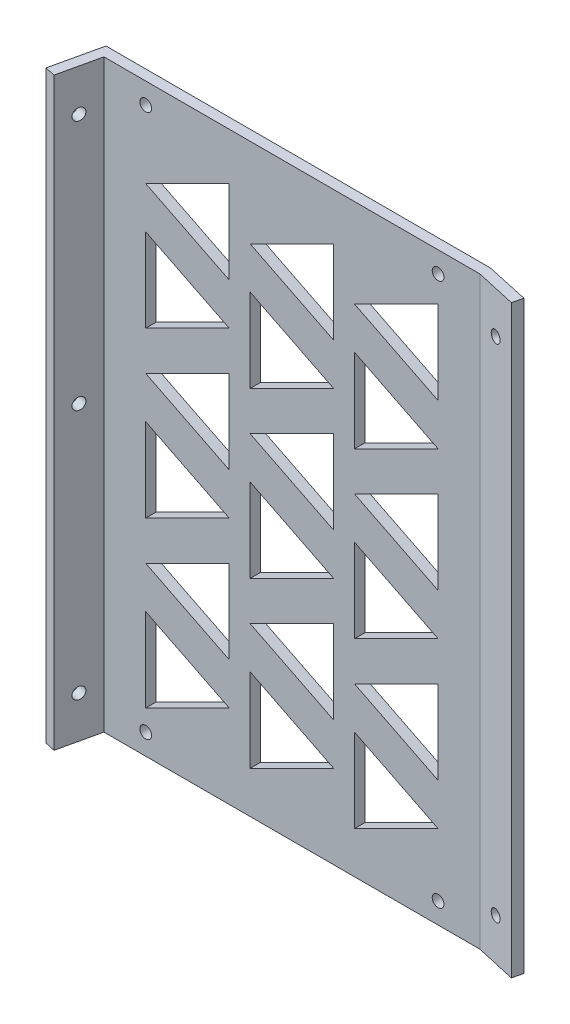
from build123d import *

# Parameters (mm, degrees)
SKETCH1_W              = 114.3
SKETCH1_H              = 177.8
BOSS_EXTRUDE1_DEPTH    = 3.175
BOSS_EXTRUDE2_DEPTH    = 177.8
SKETCH3_R              = 1.778
CUT_EXTRUDE1_DEPTH     = 203.2
CUT_EXTRUDE2_DEPTH     = 3.175
LPATTERN2_COUNT        = 3
LPATTERN2_PITCH        = 50
LPATTERN3_COUNT        = 3
LPATTERN3_PITCH        = 31.75
LPATTERN3_COPY_1_DEPTH = 3.175
LPATTERN3_COPY_2_DEPTH = 3.175
LPATTERN3_COPY_3_DEPTH = 3.175
LPATTERN3_COPY_4_DEPTH = 3.175
SKETCH5_R              = 1.778
CUT_EXTRUDE3_DEPTH     = 3.175
SKETCH6_R              = 1.778
CUT_EXTRUDE4_DEPTH     = 3.175


with BuildPart() as part:
    # Sketch1 → Boss-Extrude1 (new body)
    with BuildSketch(Plane.XY):
        with Locations((-57.15, -88.9)):
            Rectangle(SKETCH1_W, SKETCH1_H)
    extrude(amount=BOSS_EXTRUDE1_DEPTH)

    # Sketch2 → Boss-Extrude2 (add)
    with BuildSketch(Plane.XZ.offset(177.8)):
        Polygon((-114.3, 3.175), (-117.087804878, 15.565243902), (-120.185365854, 14.868292683), (-116.84, 0), (-114.3, 0), align=None)
        Polygon((0, 3.175), (0, 0), (13.087195122, 2.865243902), (12.390243902, 5.962804878), align=None)
    extrude(amount=-BOSS_EXTRUDE2_DEPTH)

    # Sketch3 → Cut-Extrude1 (cut)
    with BuildSketch(Plane(origin=(-108.112433076, 0, -24.325297442), x_dir=(0.219512195, 0, -0.975609756), z_dir=(0.975609756, 0, 0.219512195))):
        with Locations((-34.537804878, -165.1)):
            Circle(SKETCH3_R)
        with Locations((-34.537804878, -88.9)):
            Circle(SKETCH3_R)
        with Locations((-34.537804878, -12.7)):
            Circle(SKETCH3_R)
    extrude(amount=-CUT_EXTRUDE1_DEPTH, mode=Mode.SUBTRACT)

    # Sketch4 → Cut-Extrude2 (cut)
    with BuildSketch(Plane.XY.offset(3.175)):
        Polygon((-101.6, -165.1), (-101.6, -139.7), (-76.2, -152.4), align=None)
        Polygon((-101.6, -127), (-76.2, -139.7), (-76.2, -114.3), align=None)
    cut_extrude2 = extrude(amount=-CUT_EXTRUDE2_DEPTH, mode=Mode.SUBTRACT)

    # LPattern2: Cut-Extrude2 ×3
    with Locations(*[(0, i * LPATTERN2_PITCH, 0) for i in range(1, LPATTERN2_COUNT)]):
        add(cut_extrude2, mode=Mode.SUBTRACT)

    # LPattern3: Cut-Extrude2 ×3
    with Locations(*[(i * LPATTERN3_PITCH, 0, 0) for i in range(1, LPATTERN3_COUNT)]):
        add(cut_extrude2, mode=Mode.SUBTRACT)

    # LPattern3 copy 1 sketch → LPattern3 copy 1 (cut)
    with BuildSketch(Plane(origin=(31.75, 50, 3.175), x_dir=(1, 0, 0), z_dir=(0, 0, 1))):
        Polygon((-101.6, -165.1), (-101.6, -139.7), (-76.2, -152.4), align=None)
        Polygon((-101.6, -127), (-76.2, -139.7), (-76.2, -114.3), align=None)
    extrude(amount=-LPATTERN3_COPY_1_DEPTH, mode=Mode.SUBTRACT)

    # LPattern3 copy 2 sketch → LPattern3 copy 2 (cut)
    with BuildSketch(Plane(origin=(63.5, 50, 3.175), x_dir=(1, 0, 0), z_dir=(0, 0, 1))):
        Polygon((-101.6, -165.1), (-101.6, -139.7), (-76.2, -152.4), align=None)
        Polygon((-101.6, -127), (-76.2, -139.7), (-76.2, -114.3), align=None)
    extrude(amount=-LPATTERN3_COPY_2_DEPTH, mode=Mode.SUBTRACT)

    # LPattern3 copy 3 sketch → LPattern3 copy 3 (cut)
    with BuildSketch(Plane(origin=(31.75, 100, 3.175), x_dir=(1, 0, 0), z_dir=(0, 0, 1))):
        Polygon((-101.6, -165.1), (-101.6, -139.7), (-76.2, -152.4), align=None)
        Polygon((-101.6, -127), (-76.2, -139.7), (-76.2, -114.3), align=None)
    extrude(amount=-LPATTERN3_COPY_3_DEPTH, mode=Mode.SUBTRACT)

    # LPattern3 copy 4 sketch → LPattern3 copy 4 (cut)
    with BuildSketch(Plane(origin=(63.5, 100, 3.175), x_dir=(1, 0, 0), z_dir=(0, 0, 1))):
        Polygon((-101.6, -165.1), (-101.6, -139.7), (-76.2, -152.4), align=None)
        Polygon((-101.6, -127), (-76.2, -139.7), (-76.2, -114.3), align=None)
    extrude(amount=-LPATTERN3_COPY_4_DEPTH, mode=Mode.SUBTRACT)

    # Sketch5 → Cut-Extrude3 (cut)
    with BuildSketch(Plane.XY.offset(3.175)):
        with Locations((-101.6, -171.45)):
            Circle(SKETCH5_R)
        with Locations((-12.7, -171.45)):
            Circle(SKETCH5_R)
        with Locations((-12.7, -6.35)):
            Circle(SKETCH5_R)
        with Locations((-101.6, -6.35)):
            Circle(SKETCH5_R)
    extrude(amount=-CUT_EXTRUDE3_DEPTH, mode=Mode.SUBTRACT)

    # Sketch6 → Cut-Extrude4 (cut)
    with BuildSketch(Plane(origin=(-0.679952409, 0, 3.022010708), x_dir=(0.975609756, 0, 0.219512195), z_dir=(-0.219512195, 0, 0.975609756))):
        with Locations((7.04695122, -165.1)):
            Circle(SKETCH6_R)
        with Locations((7.04695122, -12.7)):
            Circle(SKETCH6_R)
    extrude(amount=-CUT_EXTRUDE4_DEPTH, mode=Mode.SUBTRACT)


solid = part.part
